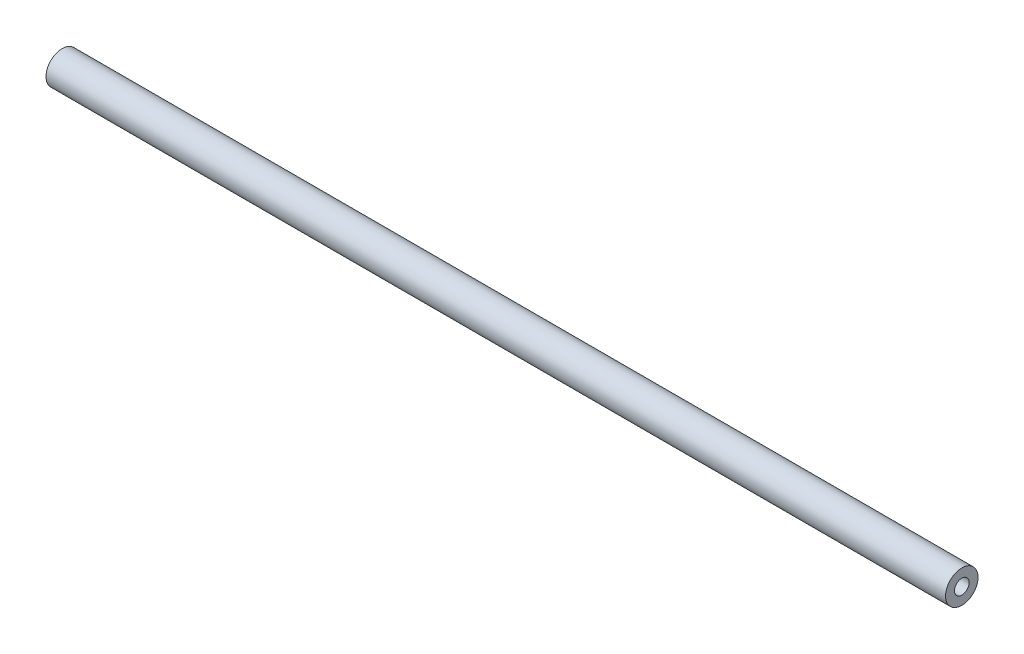
from build123d import *


with BuildPart() as part:
    # Sketch1 → Revolve1 (revolve)
    with BuildSketch(Plane.XY):
        Polygon((-613.42, 16.945076589), (-591.286245754, 16.945076589), (-588.800781823, 12.640126781), (-110.199218177, 12.640126781), (-107.713754246, 16.945076589), (-85.58, 16.945076589), (-85.58, 22.165126781), (-613.42, 22.165126781), align=None)
    revolve(axis=Axis((-686.612350473, 12.640126781, 0), (1, 0, 0)))


solid = part.part
